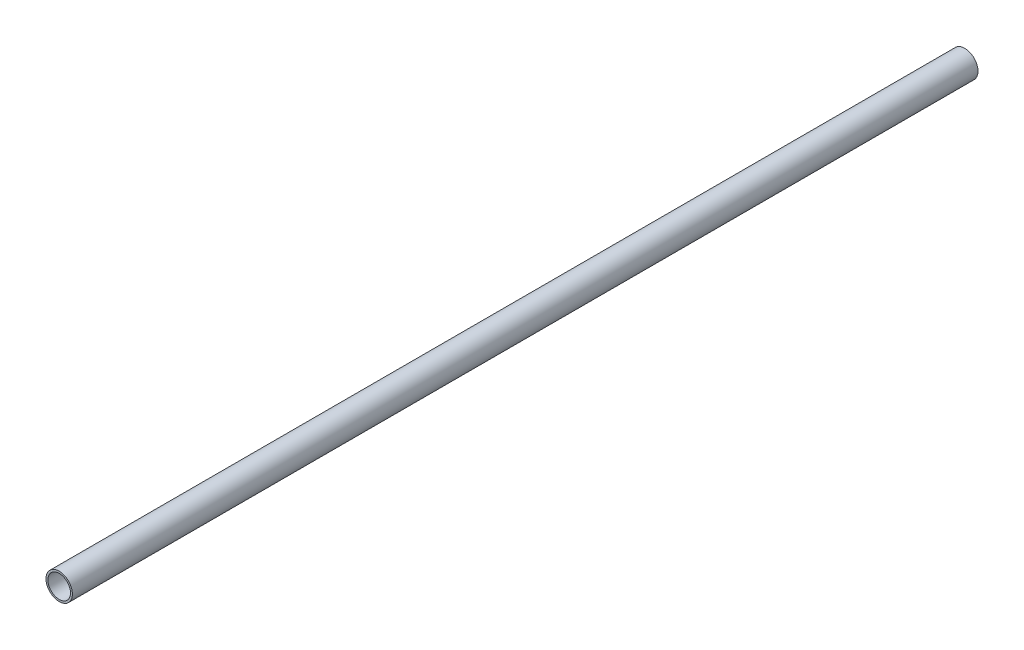
from build123d import *

# Parameters (mm, degrees)
SKETCH1_R           = 44.45
SKETCH1_R_2         = 38.1
BOSS_EXTRUDE1_DEPTH = 1524


with BuildPart() as part:
    # Sketch1 → Boss-Extrude1 (new body, symmetric)
    with BuildSketch(Plane.XY):
        Circle(SKETCH1_R)
        Circle(SKETCH1_R_2, mode=Mode.SUBTRACT)
    extrude(amount=BOSS_EXTRUDE1_DEPTH, both=True)


solid = part.part
